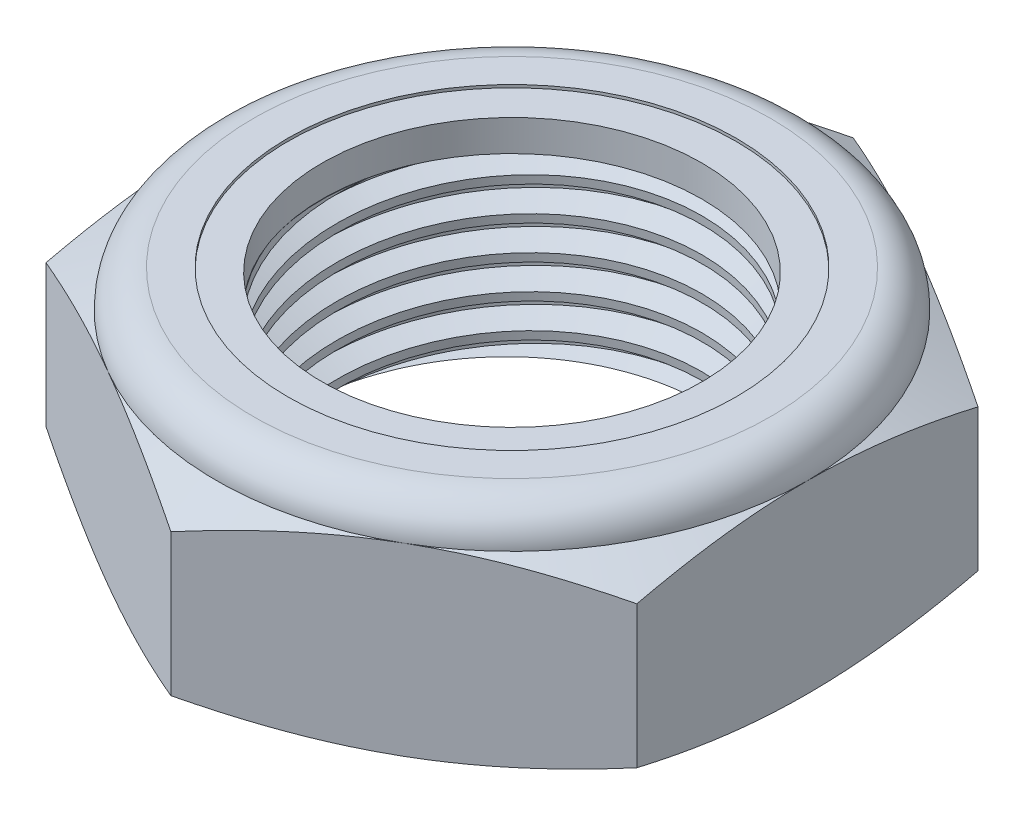
from build123d import *

# Parameters (mm, degrees)
EXTRUDE1_DEPTH      = 11.90625
SKETCH2_W           = 11.1125
SKETCH2_H           = 11.90625
LPATTERN1_COUNT     = 7
LPATTERN1_PITCH     = 1.814285714
LPATTERN1_COL_COUNT = 2
LPATTERN1_COL_PITCH = 1.814285714


with BuildPart() as part:
    # Sketch1 → Extrude1 (new body)
    with BuildSketch(Plane(origin=(0, 0, 0), x_dir=(1, 0, 0), z_dir=(0, 1, 0))):
        Polygon((0, 18.330871047), (-15.875, 9.165435523), (-15.875, -9.165435523), (0, -18.330871047), (15.875, -9.165435523), (15.875, 9.165435523), align=None)
    extrude(amount=EXTRUDE1_DEPTH)

    # Sketch4 → Cut-Revolve2 (revolve, cut)
    with BuildSketch(Plane(origin=(0, 0, 0), x_dir=(0, 0, -1), z_dir=(1, 0, 0))):
        Polygon((0, 11.90625), (11.1125, 11.90625), (10.19832589, 11.479963611), (10.19832589, 0.426286389), (11.1125, 0), (0, 0), align=None)
    revolve(axis=Axis((0, 11.90625, 0), (0, 1, 0)), mode=Mode.SUBTRACT)


with BuildPart() as body_2:
    # Sketch2 → Revolve1 (revolve)
    with BuildSketch(Plane(origin=(0, 0, 0), x_dir=(0, 0, -1), z_dir=(1, 0, 0))):
        with Locations((5.55625, 5.953125)):
            Rectangle(SKETCH2_W, SKETCH2_H)
    revolve(axis=Axis((0, -11.1125, 0), (0, 1, 0)))

    # Sketch3 → Cut-Revolve1 (revolve, cut)
    with BuildSketch(Plane(origin=(0, 0, 0), x_dir=(0, 0, -1), z_dir=(1, 0, 0))):
        Polygon((11.130951741, 11.680216167), (11.260113931, 10.09797934), (10.235229372, 10.583165537), (10.19832589, 11.035233202), align=None)
    cut_revolve1 = revolve(axis=Axis((0, 11.90625, 0.157638636), (0, -0.996684616, -0.081362009)), mode=Mode.SUBTRACT)

    # LPattern1: Cut-Revolve1 ×7
    with Locations(*[(0, -i * LPATTERN1_PITCH, 0) for i in range(1, LPATTERN1_COUNT)]):
        add(cut_revolve1, mode=Mode.SUBTRACT)

    # LPattern1 col: Cut-Revolve1 ×2
    with Locations(*[(0, i * LPATTERN1_COL_PITCH, 0) for i in range(1, LPATTERN1_COL_COUNT)]):
        add(cut_revolve1, mode=Mode.SUBTRACT)


with BuildPart() as part_1:
    add(part.part)

    # Combine1: cut body 2
    add(body_2.part, mode=Mode.SUBTRACT)

    # Sketch5 → Cut-Revolve3 (revolve, cut)
    with BuildSketch(Plane(origin=(0, 0, 0), x_dir=(0, 0, -1), z_dir=(1, 0, 0))):
        with BuildLine():
            Line((0, 0), (15.875, 0))
            Line((15.875, 0), (18.330871047, 1.145191477))
            Line((18.330871047, 1.145191477), (18.330871047, 8.776683523))
            Line((18.330871047, 8.776683523), (15.875, 9.921875))
            ThreePointArc((15.875, 9.921875), (15.293790019, 11.325040019), (13.890625, 11.90625))
            Line((13.890625, 11.90625), (13.890625, 13.17625))
            Line((13.890625, 13.17625), (19.600871047, 13.17625))
            Line((19.600871047, 13.17625), (19.600871047, -1.27))
            Line((19.600871047, -1.27), (0, -1.27))
            Line((0, -1.27), (0, 0))
        make_face()
    revolve(axis=Axis((0, 0, 0), (0, 1, 0)), mode=Mode.SUBTRACT)

    # Sketch6 → Cut-Revolve4 (revolve, cut)
    with BuildSketch(Plane(origin=(0, 0, 0), x_dir=(0, 0, -1), z_dir=(1, 0, 0))):
        with BuildLine():
            Line((0, 9.921875), (15.7226, 9.921875))
            ThreePointArc((15.7226, 9.921875), (15.186026945, 11.217276945), (13.890625, 11.75385))
            Line((13.890625, 11.75385), (12.044475445, 11.75385))
            Line((12.044475445, 11.75385), (12.044475445, 13.17625))
            Line((12.044475445, 13.17625), (0, 13.17625))
            Line((0, 13.17625), (0, 9.921875))
        make_face()
    revolve(axis=Axis((0, 13.17625, 0), (0, 1, 0)), mode=Mode.SUBTRACT)


with BuildPart() as body_2_2:
    # Sketch7 → Revolve2 (revolve)
    with BuildSketch(Plane(origin=(0, 0, 0), x_dir=(0, 0, -1), z_dir=(1, 0, 0))):
        with BuildLine():
            Line((10.19832589, 9.998075), (15.644745694, 9.998075))
            ThreePointArc((15.644745694, 9.998075), (15.104905815, 11.190050048), (13.890625, 11.67765))
            Line((13.890625, 11.67765), (10.19832589, 11.67765))
            Line((10.19832589, 11.67765), (10.19832589, 9.998075))
        make_face()
    revolve(axis=Axis((0, 9.998075, 0), (0, 1, 0)))


solid = Compound([part_1.part, body_2_2.part])
